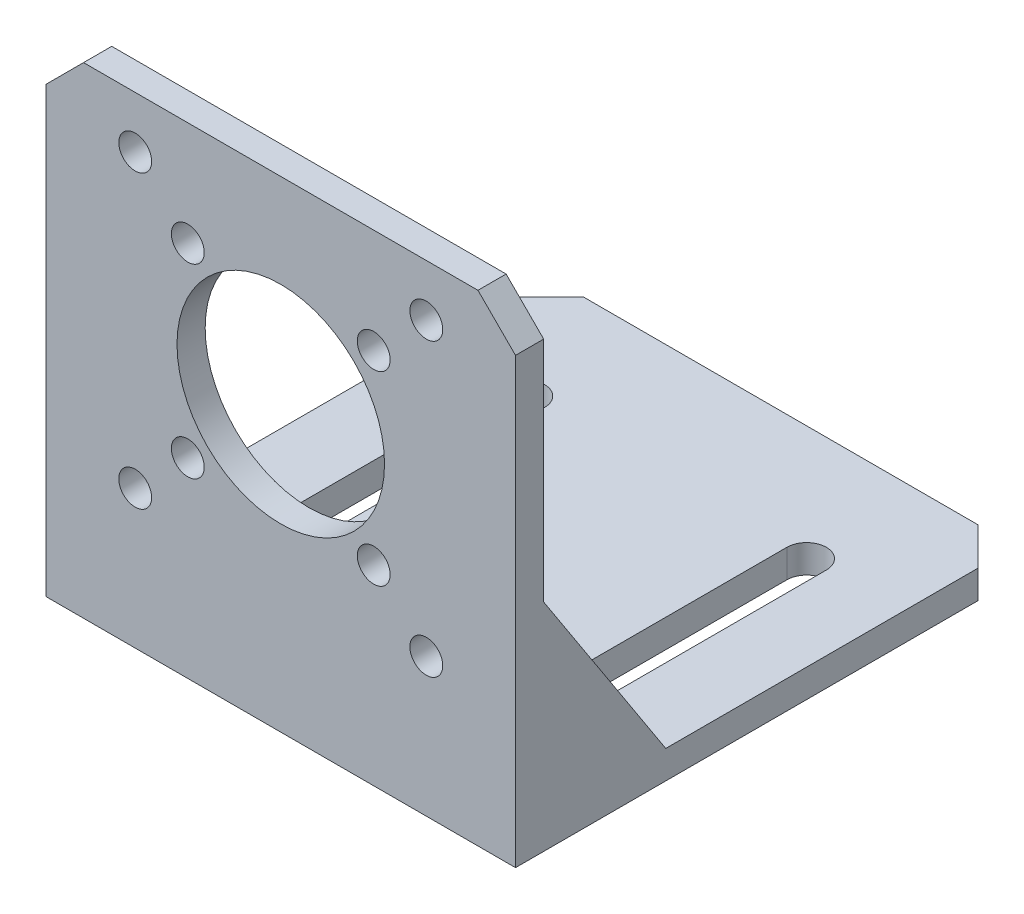
from build123d import *

# Parameters (mm, degrees)
EXTRUDE_THIN1_DEPTH = 25
SKETCH2_R           = 11.05
SKETCH2_R_2         = 1.75
CUT_EXTRUDE1_DEPTH  = 79.02002948
CHAMFER1_SIZE       = 4
CUT_EXTRUDE3_DEPTH  = 79.02002948
FILLET1_R           = 2
RIB1_REACH          = 91.231
SKETCH6_WALL_W      = 204.315201322
SKETCH6_WALL_H      = 3


with BuildPart() as part:
    # Sketch1 → Extrude-Thin1 (new, symmetric)
    with BuildSketch(Plane(origin=(0, 0, 0), x_dir=(0, 0, -1), z_dir=(1, 0, 0))):
        Polygon((0, 51.25), (0, 0), (53.25, 0), (53.25, 3), (3, 3), (3, 51.25), align=None)
    extrude(amount=EXTRUDE_THIN1_DEPTH, both=True)

    # Sketch2 → Cut-Extrude1 (cut, through all)
    with BuildSketch(Plane.XY):
        with Locations((0, 30.25)):
            Circle(SKETCH2_R)
        with Locations((-9.898989847, 40.15)):
            Circle(SKETCH2_R_2)
        with Locations((-15.5, 45.75)):
            Circle(SKETCH2_R_2)
        with Locations((9.898989847, 40.15)):
            Circle(SKETCH2_R_2)
        with Locations((15.5, 45.75)):
            Circle(SKETCH2_R_2)
        with Locations((15.5, 14.75)):
            Circle(SKETCH2_R_2)
        with Locations((9.898989847, 20.35)):
            Circle(SKETCH2_R_2)
        with Locations((-9.898989847, 20.35)):
            Circle(SKETCH2_R_2)
        with Locations((-15.5, 14.75)):
            Circle(SKETCH2_R_2)
    extrude(amount=-CUT_EXTRUDE1_DEPTH, mode=Mode.SUBTRACT)

    # Chamfer1
    chamfer1_edges = [part.edges().sort_by_distance(p)[0] for p in [
        (25, 1.5, -53.25),
        (-25, 1.5, -53.25),
        (-25, 51.25, -1.5),
        (25, 51.25, -1.5),
    ]]
    chamfer(chamfer1_edges, length=CHAMFER1_SIZE)

    # Sketch4 → Cut-Extrude3 (cut, through all)
    with BuildSketch(Plane(origin=(0, 0, 0), x_dir=(1, 0, 0), z_dir=(0, 1, 0))):
        with BuildLine():
            Line((-12.9, 41), (-12.9, 11))
            ThreePointArc((-12.9, 11), (-15, 8.9), (-17.1, 11))
            Line((-17.1, 11), (-17.1, 41))
            ThreePointArc((-17.1, 41), (-15, 43.1), (-12.9, 41))
        make_face()
        with BuildLine():
            Line((12.9, 41), (12.9, 11))
            ThreePointArc((12.9, 11), (15, 8.9), (17.1, 11))
            Line((17.1, 11), (17.1, 41))
            ThreePointArc((17.1, 41), (15, 43.1), (12.9, 41))
        make_face()
    extrude(amount=CUT_EXTRUDE3_DEPTH, mode=Mode.SUBTRACT)

    # Fillet1
    fillet1_edges = [part.edges().sort_by_distance(p)[0] for p in [
        (0, 3, -3),
    ]]
    fillet(fillet1_edges, radius=FILLET1_R)

    # Sketch6 wall → Rib1 (add, up to next)
    with BuildSketch(Plane(origin=(25, 13, -9.5), x_dir=(0, -0.838443616301, -0.544988350595), z_dir=(0, 0.544988350595, -0.838443616301)), mode=Mode.PRIVATE) as rib1_sk1:
        with Locations((0, 1.5)):
            Rectangle(SKETCH6_WALL_W, SKETCH6_WALL_H)
    rib1_tool1 = extrude(rib1_sk1.sketch, amount=-RIB1_REACH, mode=Mode.PRIVATE) - part.part
    rib1 = rib1_tool1.solids().sort_by_distance((25, 13, -9.5))[0]
    add(rib1)

    # Mirror1: Rib1 across plane
    add(rib1.mirror(Plane(origin=(0, 0, 0), x_dir=(0, 0, 1), z_dir=(1, 0, 0))))


solid = part.part
